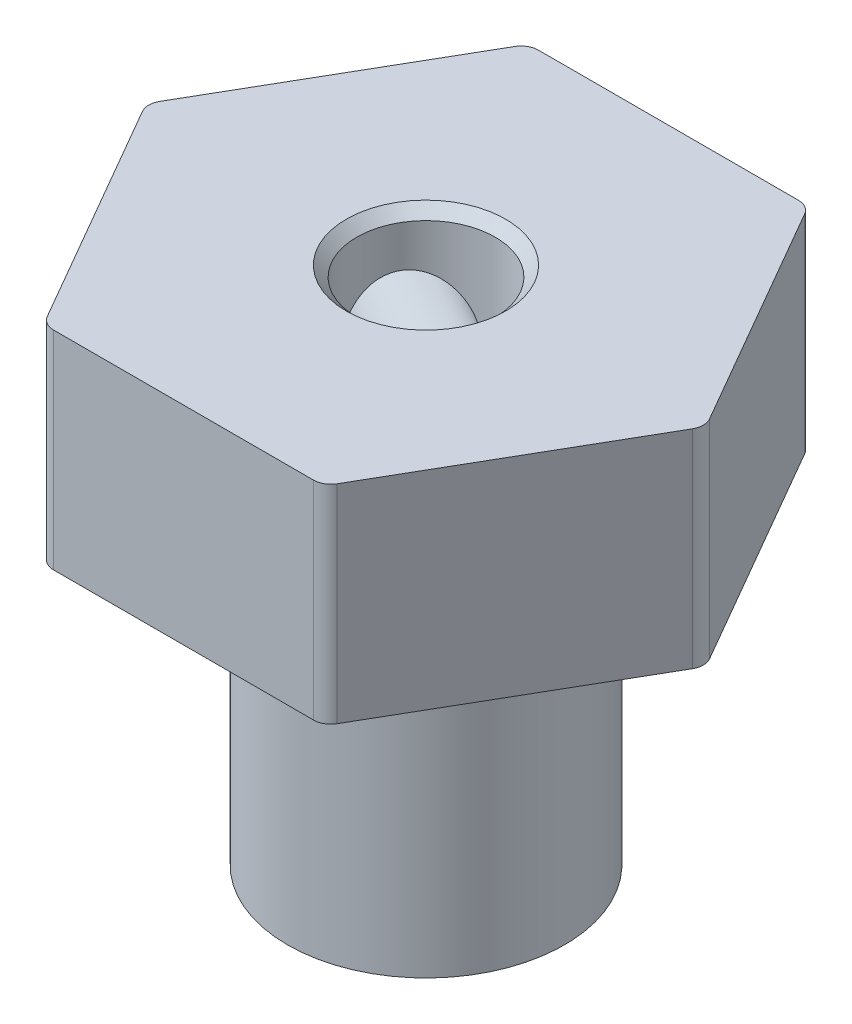
from build123d import *

# Parameters (mm, degrees)
BOSS_EXTRUDE1_DEPTH = 6
FILLET1_R           = 0.5
SKETCH2_R           = 4
BOSS_EXTRUDE2_DEPTH = 9
SKETCH4_R           = 2
CUT_EXTRUDE1_DEPTH  = 16
CHAMFER1_SIZE       = 0.3
SKETCH5_R           = 1.5
CUT_EXTRUDE2_DEPTH  = 8


with BuildPart() as part:
    # Sketch1 → Boss-Extrude1 (new body)
    with BuildSketch(Plane(origin=(0, 0, 0), x_dir=(1, 0, 0), z_dir=(0, 1, 0))):
        Polygon((8.082903769, 0), (4.041451884, 7), (-4.041451884, 7), (-8.082903769, 0), (-4.041451884, -7), (4.041451884, -7), align=None)
    extrude(amount=BOSS_EXTRUDE1_DEPTH)

    # Fillet1
    fillet1_edges = [part.edges().sort_by_distance(p)[0] for p in [
        (4.041451884, 3, 7),
        (-4.041451884, 3, 7),
        (-8.082903769, 3, 0),
        (-4.041451884, 3, -7),
        (4.041451884, 3, -7),
        (8.082903769, 3, 0),
    ]]
    fillet(fillet1_edges, radius=FILLET1_R)

    # Sketch2 → Boss-Extrude2 (add)
    with BuildSketch(Plane.XZ):
        Circle(SKETCH2_R)
    extrude(amount=BOSS_EXTRUDE2_DEPTH)

    # Sketch4 → Cut-Extrude1 (cut, through all)
    with BuildSketch(Plane(origin=(0, 6, 0), x_dir=(1, 0, 0), z_dir=(0, 1, 0))):
        Circle(SKETCH4_R)
    extrude(amount=-CUT_EXTRUDE1_DEPTH, mode=Mode.SUBTRACT)

    # Chamfer1
    chamfer1_edges = [part.edges().sort_by_distance(p)[0] for p in [
        (-2, 6, 0),
    ]]
    chamfer(chamfer1_edges, length=CHAMFER1_SIZE)

    # Sketch5 → Cut-Extrude2 (cut)
    with BuildSketch(Plane(origin=(-6.062177826, 0, -3.5), x_dir=(-0.5, 0, 0.866025404), z_dir=(-0.866025404, 0, -0.5))):
        with Locations((0, 3)):
            Circle(SKETCH5_R)
    extrude(amount=-CUT_EXTRUDE2_DEPTH, mode=Mode.SUBTRACT)


solid = part.part
